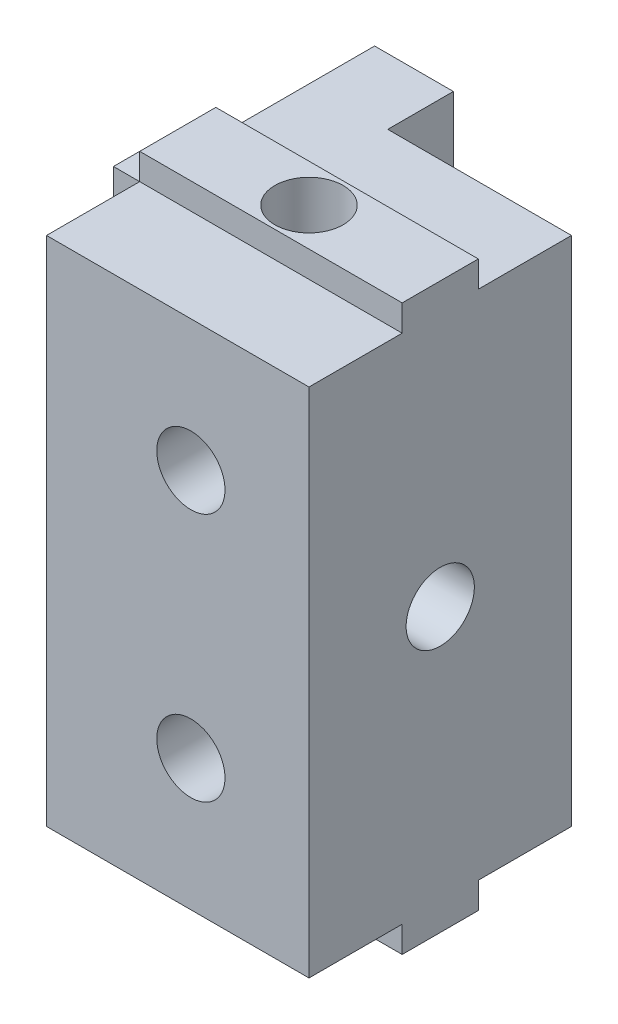
from build123d import *

# Parameters (mm, degrees)
ESQUISSE1_W                = 10
ESQUISSE1_H                = 19.5
MAIN_DEPTH                 = 5
SKETCH2_W                  = 10
SKETCH2_H                  = 2.9
MAKERBEAMSIDESUPPORT_DEPTH = 10.75
SKETCH3_W                  = 2.9
SKETCH3_H                  = 19.5
MAKERBEAMTOPSUPPORT_DEPTH  = 1
ESQUISSE2_R                = 1.3
SERVOFIXINGHOLES_DEPTH     = 10
ESQUISSE3_R                = 1.3
SIDEHOLES_DEPTH            = 2
SIDEHOLES_DEPTH_BACK       = 11
ESQUISSE4_R                = 1.3
TOPHOLES_DEPTH             = 21.5
SKETCH1_W                  = 3
SKETCH1_H                  = 19.5
BOSS_EXTRUDE1_DEPTH        = 2.5


with BuildPart() as part:
    # Esquisse1 → Main (new body, symmetric)
    with BuildSketch(Plane.XY):
        Rectangle(ESQUISSE1_W, ESQUISSE1_H)
    extrude(amount=MAIN_DEPTH, both=True)

    # Sketch2 → MakerBeamSideSupport (add, symmetric)
    with BuildSketch(Plane(origin=(0, 0, 0), x_dir=(1, 0, 0), z_dir=(0, 1, 0))):
        Rectangle(SKETCH2_W, SKETCH2_H)
    extrude(amount=MAKERBEAMSIDESUPPORT_DEPTH, both=True)

    # Sketch3 → MakerBeamTopSupport (add)
    with BuildSketch(Plane.ZY.offset(5)):
        Rectangle(SKETCH3_W, SKETCH3_H)
    extrude(amount=MAKERBEAMTOPSUPPORT_DEPTH)

    # Esquisse2 → ServoFixingHoles (cut)
    with BuildSketch(Plane(origin=(0, 0, -5), x_dir=(-1, 0, 0), z_dir=(0, 0, -1))):
        with Locations((-0.5, 4.75)):
            Circle(ESQUISSE2_R)
        with Locations((-0.5, -4.75)):
            Circle(ESQUISSE2_R)
    extrude(amount=-SERVOFIXINGHOLES_DEPTH, mode=Mode.SUBTRACT)

    # Esquisse3 → SideHoles (cut, two sides)
    with BuildSketch(Plane.ZY.offset(5)) as sideholes_sk:
        Circle(ESQUISSE3_R)
    extrude(amount=SIDEHOLES_DEPTH, mode=Mode.SUBTRACT)
    extrude(sideholes_sk.sketch, amount=-SIDEHOLES_DEPTH_BACK, mode=Mode.SUBTRACT)

    # Esquisse4 → TopHoles (cut, through all)
    with BuildSketch(Plane.XZ.offset(9.75)):
        Circle(ESQUISSE4_R)
    extrude(amount=-TOPHOLES_DEPTH, mode=Mode.SUBTRACT)

    # Sketch1 → Boss-Extrude1 (add)
    with BuildSketch(Plane(origin=(0, 0, -5), x_dir=(-1, 0, 0), z_dir=(0, 0, -1))):
        with Locations((3.5, 0)):
            Rectangle(SKETCH1_W, SKETCH1_H)
    extrude(amount=BOSS_EXTRUDE1_DEPTH)


solid = part.part
